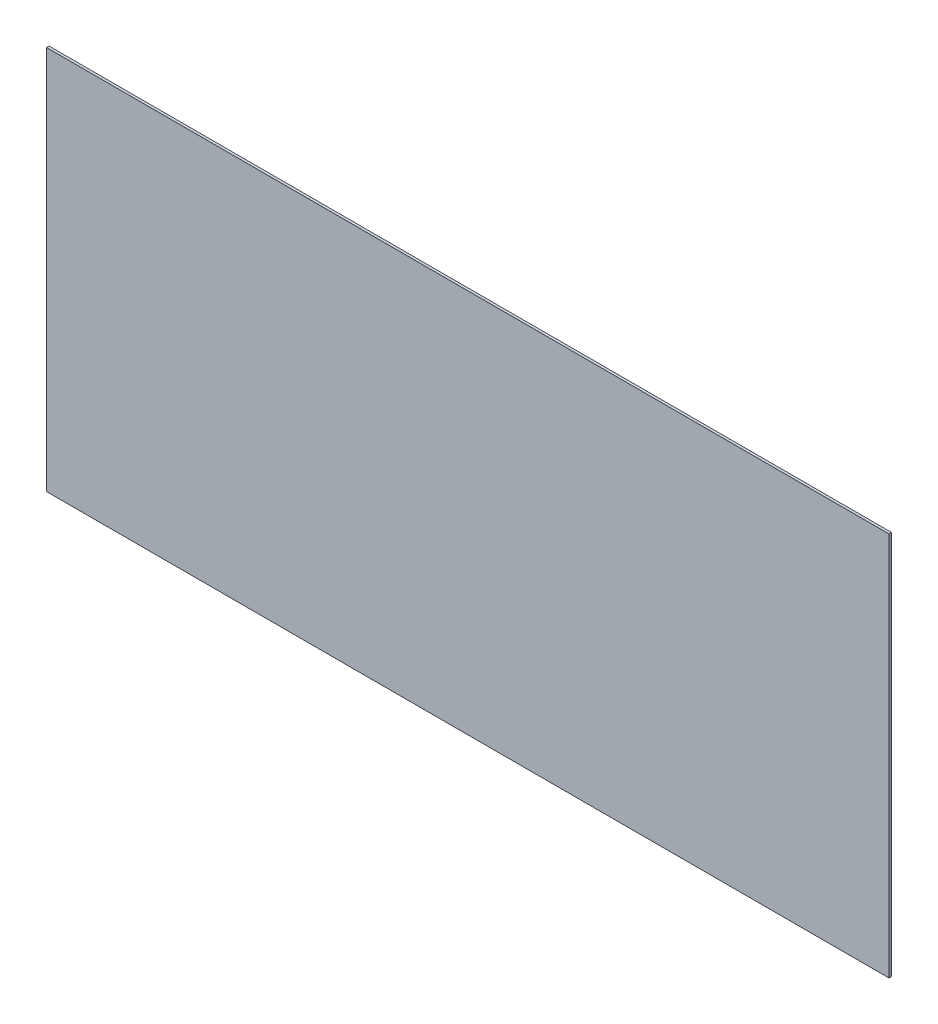
from build123d import *

# Parameters (mm, degrees)
SKETCH1_W           = 990.6
SKETCH1_H           = 452.12
BOSS_EXTRUDE1_DEPTH = 2.9972


with BuildPart() as part:
    # Sketch1 → Boss-Extrude1 (new body)
    with BuildSketch(Plane.XY):
        Rectangle(SKETCH1_W, SKETCH1_H)
    extrude(amount=BOSS_EXTRUDE1_DEPTH)


solid = part.part
